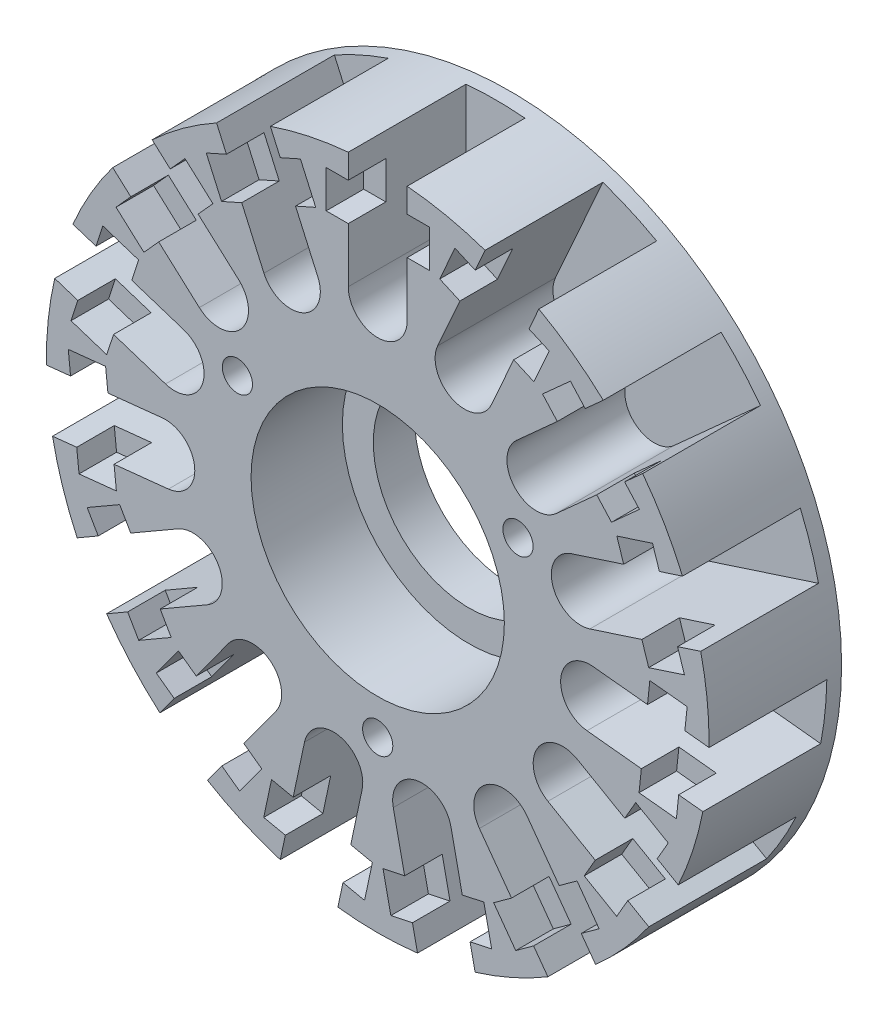
from build123d import *

# Parameters (mm, degrees)
SKETCH1_W                                = 22.5
SKETCH1_H                                = 9
CUT_EXTRUDE1_DEPTH                       = 8
SKETCH3_W                                = 2.55
SKETCH3_H                                = 2.55
CUT_EXTRUDE2_DEPTH                       = 1.5
SKETCH4_W                                = 2.55
SKETCH4_H                                = 2.55
CUT_EXTRUDE3_DEPTH                       = 1.5
F_2_05_2_05_DIAMETER_HOLE1_D             = 2.05
F_2_05_2_05_DIAMETER_HOLE1_DEPTH         = 8
F_2_05_2_05_DIAMETER_HOLE1_TIP           = 0.615882135
CBORE_FOR_M12_HEX_HEAD_BOLT1_D           = 13
CBORE_FOR_M12_HEX_HEAD_BOLT1_DEPTH       = 9
CBORE_FOR_M12_HEX_HEAD_BOLT1_CBORE_D     = 17.2
CBORE_FOR_M12_HEX_HEAD_BOLT1_CBORE_DEPTH = 6.2
F_2_5_2_5_DIAMETER_HOLE1_D               = 2.5
F_2_5_2_5_DIAMETER_HOLE1_DEPTH           = 5
F_2_5_2_5_DIAMETER_HOLE1_TIP             = 0.751075774
CIRPATTERN1_COUNT                        = 15


with BuildPart() as part:
    # Sketch1 → Revolve1 (revolve)
    with BuildSketch(Plane(origin=(0, 0, 0), x_dir=(1, 0, 0), z_dir=(0, 1, 0))):
        with Locations((11.25, -4.5)):
            Rectangle(SKETCH1_W, SKETCH1_H)
    revolve(axis=Axis((0, 0, 0), (0, 0, 1)))

    # Sketch2 → Cut-Extrude1 (cut)
    with BuildSketch(Plane.XY.offset(9)):
        with BuildLine():
            Line((-1.999999998, 22.410934831), (-1.999999998, 14.5))
            ThreePointArc((-1.999999998, 14.5), (3e-09, 12.499999999), (2.000000005, 14.5))
            Line((2.000000005, 14.5), (2.000000005, 22.410934831))
            ThreePointArc((2.000000005, 22.410934831), (3e-09, 22.5), (-1.999999998, 22.410934831))
        make_face()
    cut_extrude1 = extrude(amount=-CUT_EXTRUDE1_DEPTH, mode=Mode.SUBTRACT)

    # Sketch3 → Cut-Extrude2 (cut)
    with BuildSketch(Plane.ZY.offset(-2.000000005)):
        with Locations((7.725, 19.485934831)):
            Rectangle(SKETCH3_W, SKETCH3_H)
    cut_extrude2 = extrude(amount=-CUT_EXTRUDE2_DEPTH, mode=Mode.SUBTRACT)

    # Sketch4 → Cut-Extrude3 (cut)
    with BuildSketch(Plane(origin=(-1.999999998, 0, 0), x_dir=(0, 0, -1), z_dir=(1, 0, 0))):
        with Locations((-7.725, 19.485934831)):
            Rectangle(SKETCH4_W, SKETCH4_H)
    cut_extrude3 = extrude(amount=-CUT_EXTRUDE3_DEPTH, mode=Mode.SUBTRACT)

    # Ø2.05 (2.05) Diameter Hole1
    with Locations(Plane.XY.offset(9)):
        with Locations((9.526279442, 5.5), (0, -11), (-9.526279442, 5.5)):
            Hole(F_2_05_2_05_DIAMETER_HOLE1_D / 2, depth=F_2_05_2_05_DIAMETER_HOLE1_DEPTH)
            with Locations((0, 0, -(F_2_05_2_05_DIAMETER_HOLE1_DEPTH + F_2_05_2_05_DIAMETER_HOLE1_TIP / 2))):  # 118° drill point
                Cone(0, F_2_05_2_05_DIAMETER_HOLE1_D / 2, F_2_05_2_05_DIAMETER_HOLE1_TIP, mode=Mode.SUBTRACT)

    # CBORE for M12 Hex Head Bolt1
    with Locations(Plane.XY.offset(9)):
        with Locations((0, 0)):
            CounterBoreHole(CBORE_FOR_M12_HEX_HEAD_BOLT1_D / 2, CBORE_FOR_M12_HEX_HEAD_BOLT1_CBORE_D / 2, CBORE_FOR_M12_HEX_HEAD_BOLT1_CBORE_DEPTH, depth=CBORE_FOR_M12_HEX_HEAD_BOLT1_DEPTH)

    # Ø2.5 (2.5) Diameter Hole1
    with Locations(Plane(origin=(0, 0, 0), x_dir=(-1, 0, 0), z_dir=(0, 0, -1))):
        with Locations((16.887495374, 9.75), (-16.887495374, 9.75), (0, -19.5)):
            Hole(F_2_5_2_5_DIAMETER_HOLE1_D / 2, depth=F_2_5_2_5_DIAMETER_HOLE1_DEPTH)
            with Locations((0, 0, -(F_2_5_2_5_DIAMETER_HOLE1_DEPTH + F_2_5_2_5_DIAMETER_HOLE1_TIP / 2))):  # 118° drill point
                Cone(0, F_2_5_2_5_DIAMETER_HOLE1_D / 2, F_2_5_2_5_DIAMETER_HOLE1_TIP, mode=Mode.SUBTRACT)

    # CirPattern1: Cut-Extrude1, Cut-Extrude2, Cut-Extrude3 ×15 about axis
    cirpattern1_axis = Axis((0, 0, 0), (0, 0, 1))
    for i in range(1, CIRPATTERN1_COUNT):
        add(cut_extrude1.rotate(cirpattern1_axis, i * 360 / CIRPATTERN1_COUNT), mode=Mode.SUBTRACT)
        add(cut_extrude2.rotate(cirpattern1_axis, i * 360 / CIRPATTERN1_COUNT), mode=Mode.SUBTRACT)
        add(cut_extrude3.rotate(cirpattern1_axis, i * 360 / CIRPATTERN1_COUNT), mode=Mode.SUBTRACT)


solid = part.part
